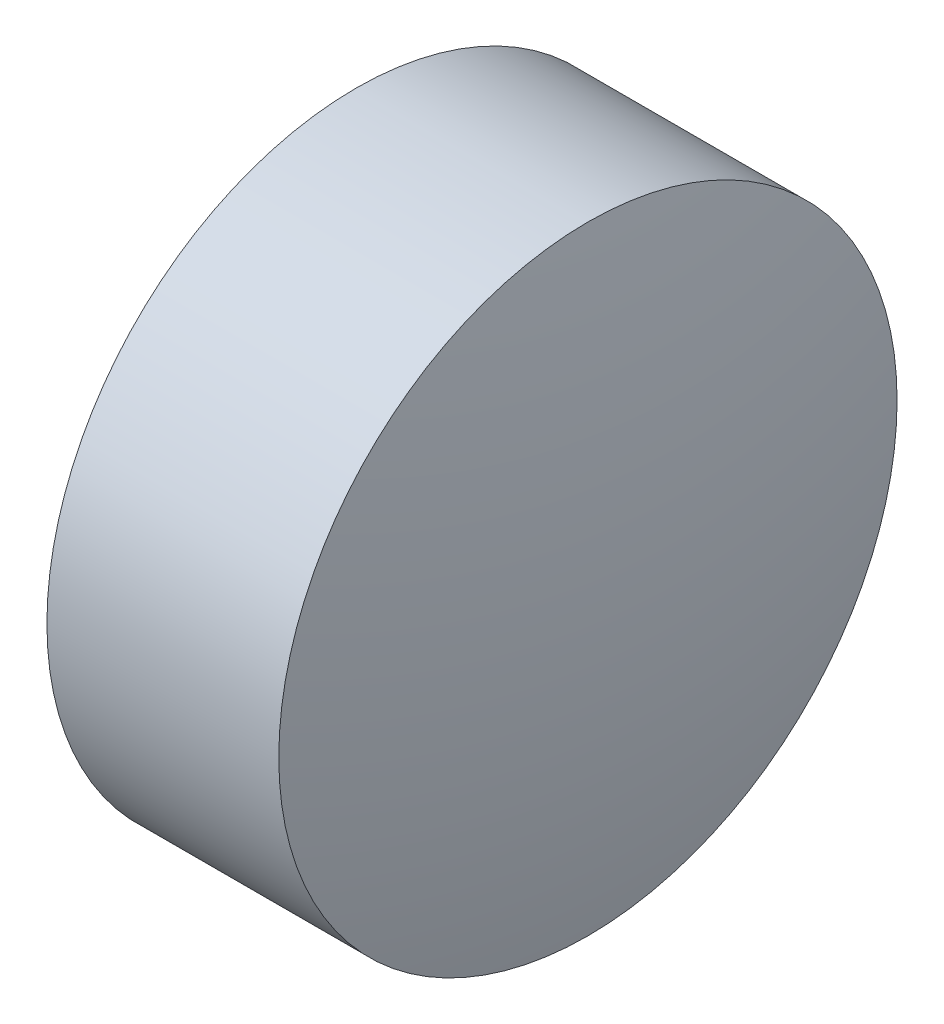
from build123d import *


with BuildPart() as part:
    # 草图1 → 旋转1 (revolve)
    with BuildSketch(Plane.XY, mode=Mode.PRIVATE) as revolve_1_sk:
        with BuildLine():
            Line((701.633864429, 219.547615513), (701.633864429, 221.547615513))
            Line((701.633864429, 221.547615513), (703.133864429, 221.547615513))
            ThreePointArc((703.133864429, 221.547615513), (703.298699053, 220.553647322), (703.353864429, 219.547615513))
            Line((703.353864429, 219.547615513), (701.633864429, 219.547615513))
        make_face()
    revolve(revolve_1_sk.sketch.rotate(Axis((701.205757735, 219.547615513, 0), (1, 0, 0)), 180), axis=Axis((701.205757735, 219.547615513, 0), (1, 0, 0)))  # turned: the seam where the file's is


solid = part.part
